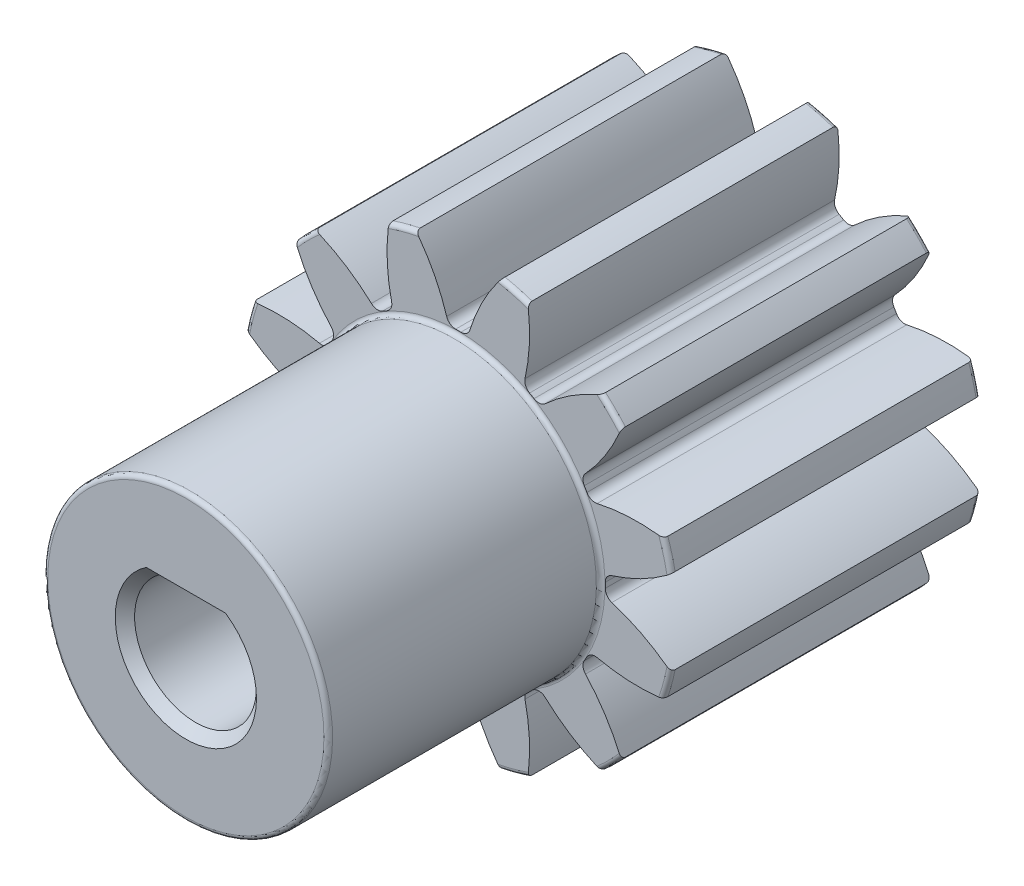
from build123d import *

# Parameters (mm, degrees)
FILLET2_R           = 0.1778
CUT_EXTRUDE2_DEPTH  = 13.7
CIRPATTERN1_COUNT   = 12
BOSS_EXTRUDE1_DEPTH = 23.876
CHAMFER1_SIZE       = 0.396875


with BuildPart() as part:
    # Sketch4 → Revolve1 (revolve)
    with BuildSketch(Plane(origin=(0, 0, 0), x_dir=(0, 0, -1), z_dir=(1, 0, 0))):
        Polygon((-23.876, 2.499999953), (-23.876, 5.842), (-12.7, 5.842), (-12.7, 8.89), (0, 8.89), (0, 2.499999953), align=None)
    revolve(axis=Axis((0, 0, 12.7), (0, 0, 1)))

    # Fillet2
    fillet2_edges = [part.edges().sort_by_distance(p)[0] for p in [
        (0, -8.89, 0),
        (0, -8.89, 12.7),
        (0, -5.842, 12.7),
        (0, -5.842, 23.876),
    ]]
    fillet(fillet2_edges, radius=FILLET2_R)

    # Sketch7 → Cut-Extrude2 (cut, through all)
    with BuildSketch(Plane.XY.offset(12.7)):
        with BuildLine():
            ThreePointArc((-0.106859198, 6.031553478), (0, 6.0325), (0.106859198, 6.031553478))
            ThreePointArc((0.106859198, 6.031553478), (0.336785051, 6.10369389), (0.477444541, 6.299359534))
            ThreePointArc((0.477444541, 6.299359534), (1.000242993, 7.565612146), (1.7413194, 8.717792539))
            ThreePointArc((1.7413194, 8.717792539), (0, 8.89), (-1.7413194, 8.717792539))
            ThreePointArc((-1.7413194, 8.717792539), (-1.000242993, 7.565612146), (-0.477444541, 6.299359534))
            ThreePointArc((-0.477444541, 6.299359534), (-0.336785051, 6.10369389), (-0.106859198, 6.031553478))
        make_face()
    cut_extrude2 = extrude(amount=-CUT_EXTRUDE2_DEPTH, mode=Mode.SUBTRACT)

    # CirPattern1: Cut-Extrude2 ×12 about axis
    cirpattern1_axis = Axis((0, 0, 0), (0, 0, 1))
    for i in range(1, CIRPATTERN1_COUNT):
        add(cut_extrude2.rotate(cirpattern1_axis, i * 360 / CIRPATTERN1_COUNT), mode=Mode.SUBTRACT)

    # Sketch8 → Boss-Extrude1 (add)
    with BuildSketch(Plane(origin=(0, 0, 0), x_dir=(-1, 0, 0), z_dir=(0, 0, -1))):
        with BuildLine():
            Line((-1.499999984, 1.999999953), (1.499999984, 1.999999953))
            ThreePointArc((1.499999984, 1.999999953), (0, 2.499999953), (-1.499999984, 1.999999953))
        make_face()
    extrude(amount=-BOSS_EXTRUDE1_DEPTH)

    # Chamfer1
    chamfer1_edges = [part.edges().sort_by_distance(p)[0] for p in [
        (0, 1.999999953, 0),
        (0, 1.999999953, 23.876),
        (0, -2.499999953, 0),
        (0, -2.499999953, 23.876),
    ]]
    chamfer(chamfer1_edges, length=CHAMFER1_SIZE)


solid = part.part
